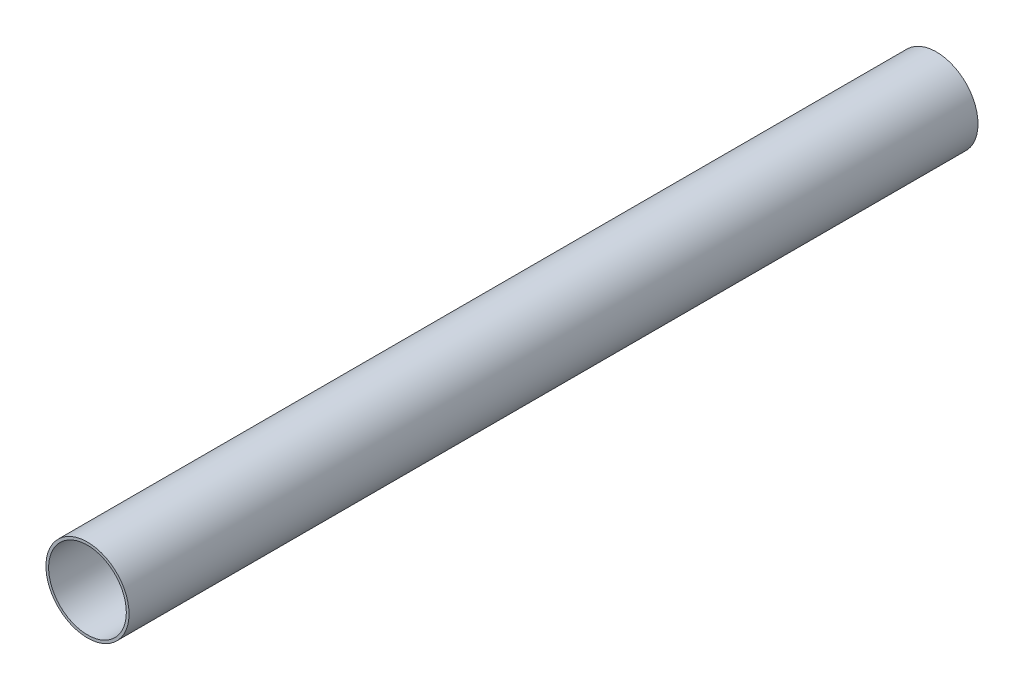
from build123d import *

# Parameters (mm, degrees)
SKETCH1_R      = 49.2125
SKETCH1_R_2    = 46.0121
EXTRUDE1_DEPTH = 1005.332


with BuildPart() as part:
    # Sketch1 → Extrude1 (new body)
    with BuildSketch(Plane.XY):
        Circle(SKETCH1_R)
        Circle(SKETCH1_R_2, mode=Mode.SUBTRACT)
    extrude(amount=EXTRUDE1_DEPTH)


solid = part.part
